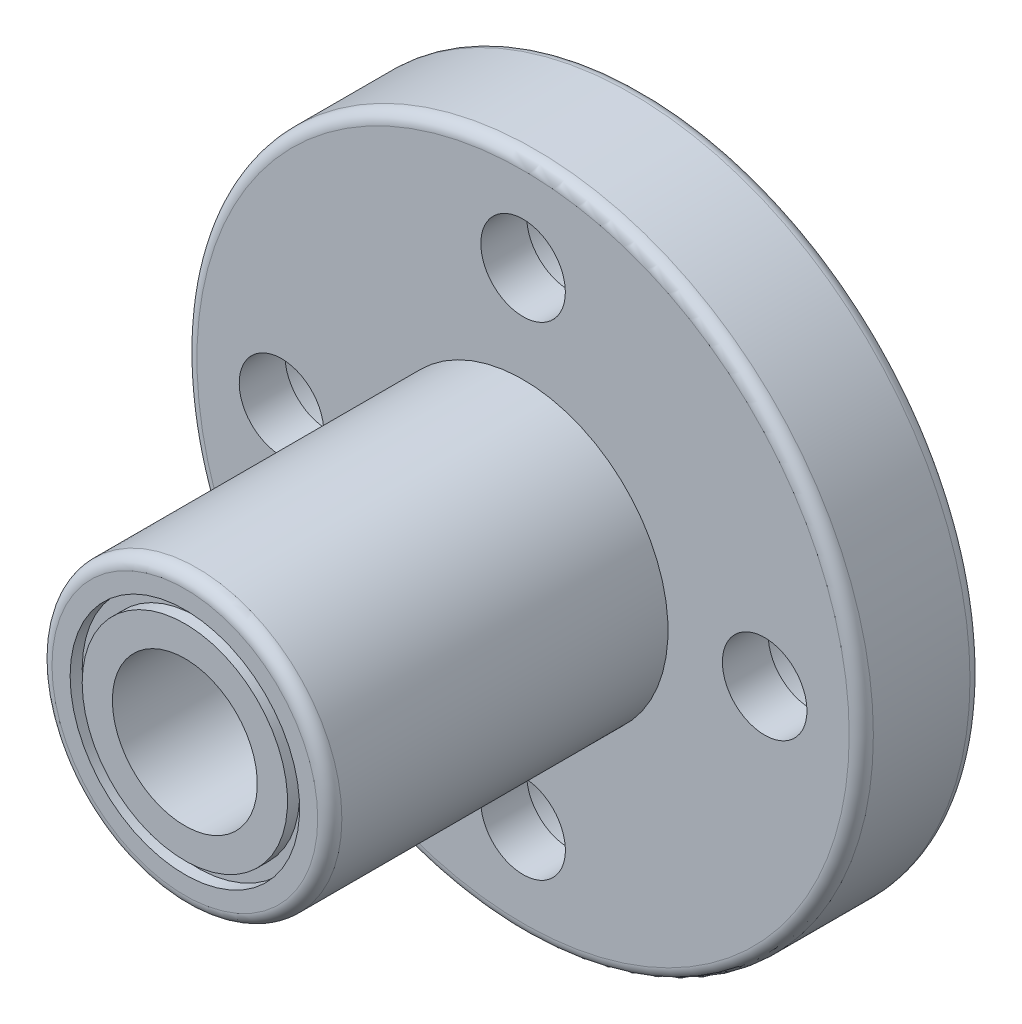
from build123d import *

# Parameters (mm, degrees)
PADR_OCIRCULAR1_COUNT = 4
FILETE1_R             = 0.5


with BuildPart() as part:
    # Esboço1 → Revolução1 (revolve)
    with BuildSketch(Plane(origin=(0, 0, 0), x_dir=(0, 0, -1), z_dir=(-1, 0, 0)), mode=Mode.PRIVATE) as revolu_o1_sk:
        Polygon((0, 3), (0, 4.25), (-0.5, 4.25), (-0.5, 4.75), (0, 4.75), (0, 5.5), (-0.5, 5.5), (-0.5, 6), (0, 6), (0, 14), (-5, 14), (-5, 6), (-19, 6), (-19, 4.75), (-18.5, 4.75), (-18.5, 4.25), (-19, 4.25), (-19, 3), align=None)
    revolve(revolu_o1_sk.sketch.rotate(Axis((0, 0, 0), (0, 0, 1)), 270), axis=Axis((0, 0, 0), (0, 0, 1)))  # turned: the seam where the file's is

    # Esboço5 → Corte-Revolução1 (revolve, cut)
    with BuildSketch(Plane(origin=(0, 0, 0), x_dir=(0, 0, -1), z_dir=(1, 0, 0)), mode=Mode.PRIVATE) as corte_revolu_o1_sk:
        Polygon((0, 13), (-3.1, 13), (-3.1, 11.75), (-5, 11.75), (-5, 10), (0, 10), align=None)
    corte_revolu_o1 = revolve(corte_revolu_o1_sk.sketch.rotate(Axis((0, 10, 0), (0, 0, -1)), 90), axis=Axis((0, 10, 0), (0, 0, -1)), mode=Mode.SUBTRACT)  # turned: the seam where the file's is

    # PadrãoCircular1: Corte-Revolução1 ×4 about axis
    padr_ocircular1_axis = Axis((0, 0, 0), (0, 0, 1))
    for i in range(1, PADR_OCIRCULAR1_COUNT):
        add(corte_revolu_o1.rotate(padr_ocircular1_axis, i * 360 / PADR_OCIRCULAR1_COUNT), mode=Mode.SUBTRACT)

    # Filete1
    filete1_edges = [part.edges().sort_by_distance(p)[0] for p in [
        (6, 0, 19),
        (14, 0, 5),
        (14, 0, 0),
    ]]
    fillet(filete1_edges, radius=FILETE1_R)


solid = part.part
